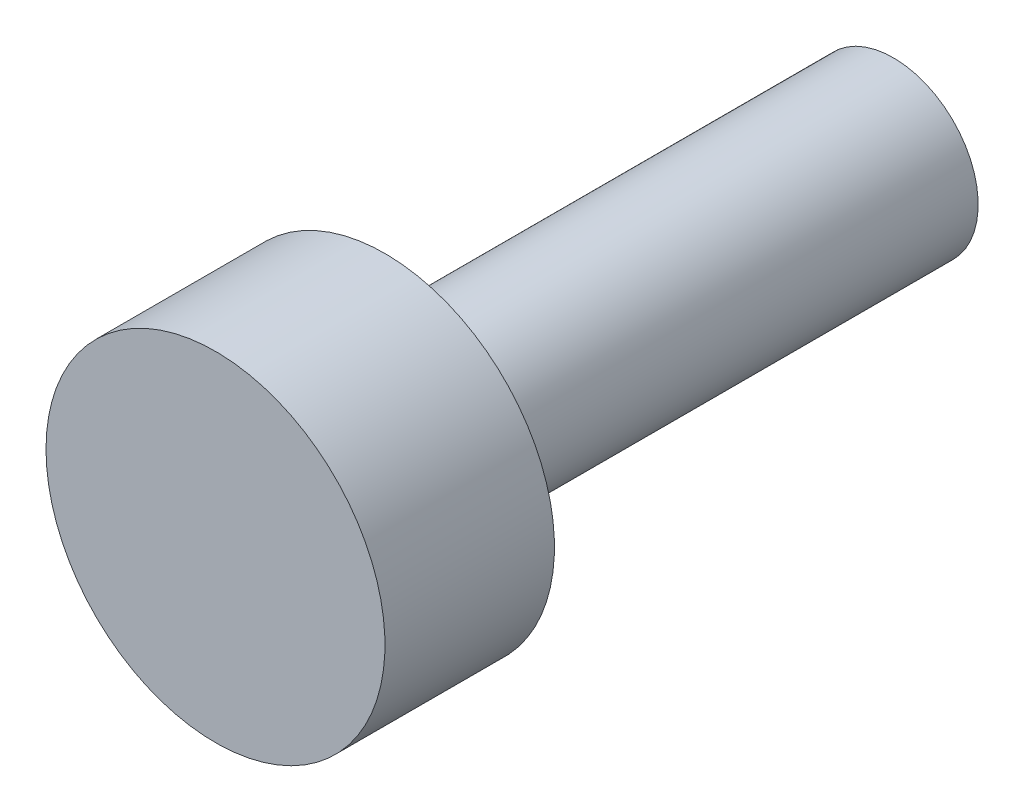
from build123d import *


with BuildPart() as part:
    # Croquis1 → Revolución1 (revolve)
    with BuildSketch(Plane(origin=(0, 0, 0), x_dir=(1, 0, 0), z_dir=(0, 1, 0))):
        Polygon((0, 8.532608696), (0, -11.467391304), (-5, -11.467391304), (-5, -6.467391304), (-2.5, -6.467391304), (-2.5, 8.532608696), align=None)
    revolve(axis=Axis((0, 0, -8.532608696), (0, 0, 1)))


solid = part.part
